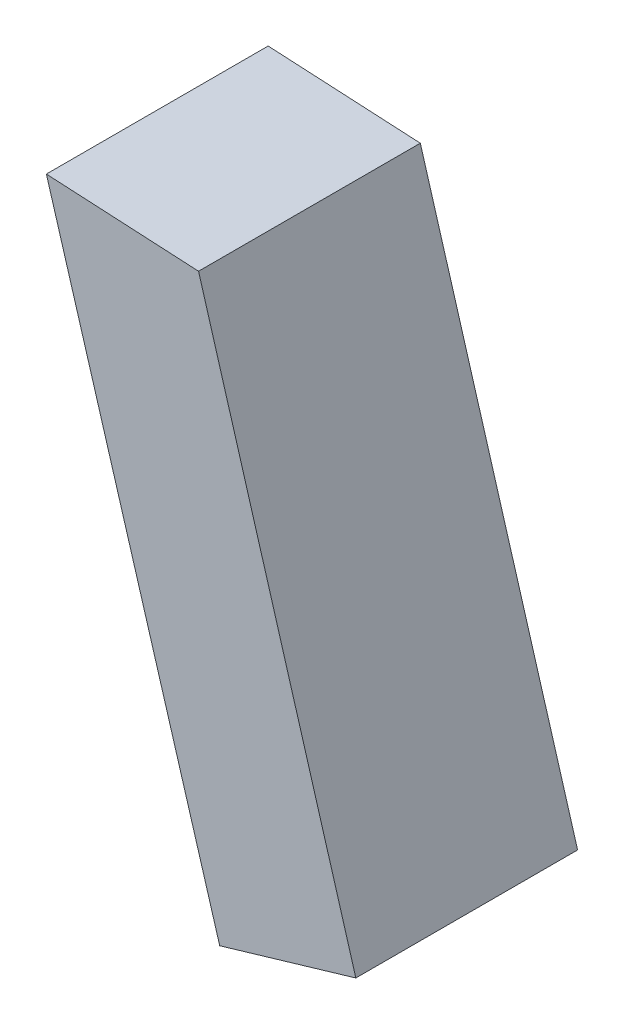
from build123d import *

# Parameters (mm, degrees)
BOSS_EXTRUDE1_DEPTH = 0.5


with BuildPart() as part:
    # Sketch1 → Boss-Extrude1 (new body)
    with BuildSketch(Plane(origin=(0, 0, -0.375), x_dir=(-1, 0, 0), z_dir=(0, 0, -1))):
        Polygon((-1.681917069, 0.955633573), (-2.036614991, -0.246978501), (-1.729686411, -0.337503893), (-1.338882758, 0.973862853), align=None)
    extrude(amount=-BOSS_EXTRUDE1_DEPTH)


solid = part.part
